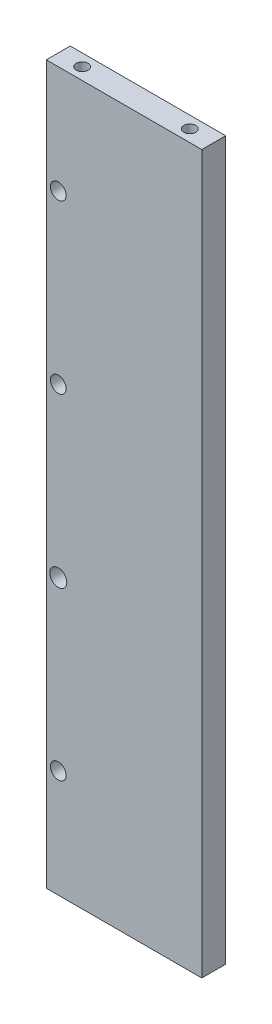
from build123d import *

# Parameters (mm, degrees)
SKETCH1_W             = 65
SKETCH1_H             = 300
BOSS_EXTRUDE1_DEPTH   = 10
M6_TAPPED_HOLE1_D     = 5
M6_TAPPED_HOLE1_DEPTH = 20
M6_TAPPED_HOLE1_TIP   = 1.502151548
M6_TAPPED_HOLE2_D     = 5
M6_TAPPED_HOLE2_DEPTH = 23
M6_TAPPED_HOLE2_TIP   = 1.502151548
SKETCH9_R             = 3.3
SKETCH9_R_2           = 3.555070432
CUT_EXTRUDE1_DEPTH    = 11


with BuildPart() as part:
    # Sketch1 → Boss-Extrude1 (new body)
    with BuildSketch(Plane.XY):
        with Locations((32.5, 150)):
            Rectangle(SKETCH1_W, SKETCH1_H)
    extrude(amount=BOSS_EXTRUDE1_DEPTH)

    # M6 Tapped Hole1
    with Locations(Plane(origin=(0, 0, 0), x_dir=(-1, 0, 0), z_dir=(0, -1, 0))):
        with Locations((-55, -5), (-10, -5)):
            Hole(M6_TAPPED_HOLE1_D / 2, depth=M6_TAPPED_HOLE1_DEPTH)
            with Locations((0, 0, -(M6_TAPPED_HOLE1_DEPTH + M6_TAPPED_HOLE1_TIP / 2))):  # 118° drill point
                Cone(0, M6_TAPPED_HOLE1_D / 2, M6_TAPPED_HOLE1_TIP, mode=Mode.SUBTRACT)

    # M6 Tapped Hole2
    with Locations(Plane(origin=(0, 300, 0), x_dir=(1, 0, 0), z_dir=(0, 1, 0))):
        with Locations((10, -5), (55, -5)):
            Hole(M6_TAPPED_HOLE2_D / 2, depth=M6_TAPPED_HOLE2_DEPTH)
            with Locations((0, 0, -(M6_TAPPED_HOLE2_DEPTH + M6_TAPPED_HOLE2_TIP / 2))):  # 118° drill point
                Cone(0, M6_TAPPED_HOLE2_D / 2, M6_TAPPED_HOLE2_TIP, mode=Mode.SUBTRACT)

    # Sketch9 → Cut-Extrude1 (cut, through all)
    with BuildSketch(Plane.XY.offset(10)):
        with Locations((5, 255)):
            Circle(SKETCH9_R)
        with Locations((5, 185)):
            Circle(SKETCH9_R)
        with Locations((5, 45)):
            Circle(SKETCH9_R)
        with Locations((5, 115)):
            Circle(SKETCH9_R_2)
    extrude(amount=-CUT_EXTRUDE1_DEPTH, mode=Mode.SUBTRACT)


solid = part.part
